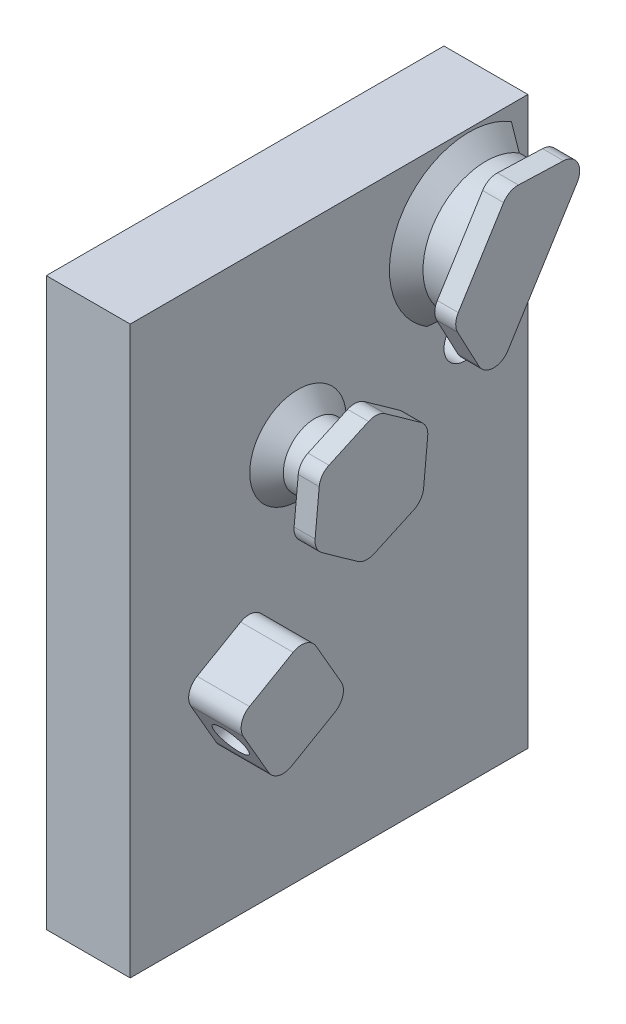
from build123d import *

# Parameters (mm, degrees)
SKETCH1_W           = 60.198
SKETCH1_H           = 85.725
SKETCH1_R           = 3.175
BOSS_EXTRUDE1_DEPTH = 12.7
SKETCH3_R           = 4.7625
BOSS_EXTRUDE2_DEPTH = 7.9375
BOSS_EXTRUDE3_DEPTH = 3.175
BOSS_EXTRUDE4_DEPTH = 3.175
FILLET1_R           = 2.54
CHAMFER1_SIZE       = 2.54
SKETCH15_R          = 2.54
CUT_EXTRUDE1_DEPTH  = 12.7


with BuildPart() as part:
    # Sketch1 → Boss-Extrude1 (new body)
    with BuildSketch(Plane(origin=(0, 0, 0), x_dir=(0, 0, -1), z_dir=(1, 0, 0))):
        with Locations((30.099, 42.8625)):
            Rectangle(SKETCH1_W, SKETCH1_H)
        with Locations((50.673, 58.7375)):
            Circle(SKETCH1_R, mode=Mode.SUBTRACT)
    extrude(amount=-BOSS_EXTRUDE1_DEPTH)

    # Sketch3 → Boss-Extrude2 (add)
    with BuildSketch(Plane(origin=(0, 0, 0), x_dir=(0, 0, -1), z_dir=(1, 0, 0))):
        with Locations((25.4, 57.15)):
            Circle(SKETCH3_R)
        Polygon((18.923, 39.573522628), (25.273, 28.575), (14.274477372, 22.225), (7.924477372, 33.223522628), align=None)
        with BuildLine():
            Line((56.355023328, 81.24857189), (46.259909872, 65.09335031))
            ThreePointArc((46.259909872, 65.09335031), (43.22985581, 78.218517828), (56.355023328, 81.24857189))
        make_face()
    extrude(amount=BOSS_EXTRUDE2_DEPTH)

    # Sketch10 → Boss-Extrude3 (add)
    with BuildSketch(Plane(origin=(7.9375, 0, 0), x_dir=(0, 0, -1), z_dir=(1, 0, 0))):
        Polygon((26.305931595, 66.631820128), (17.641468693, 62.67546984), (16.735537097, 53.193649712), (24.494068405, 47.668179872), (33.158531307, 51.62453016), (34.064462903, 61.106350288), align=None)
    extrude(amount=BOSS_EXTRUDE3_DEPTH)

    # Sketch14 → Boss-Extrude4 (add)
    with BuildSketch(Plane(origin=(7.9375, 0, 0), x_dir=(0, 0, -1), z_dir=(1, 0, 0))):
        Polygon((51.3074666, 73.1709611), (58.881956407, 85.29242578), (46.18969706, 85.735768391), (37.770793083, 72.262986752), (43.732976793, 61.04949642), align=None)
    extrude(amount=BOSS_EXTRUDE4_DEPTH)

    # Fillet1
    fillet1_edges = [part.edges().sort_by_distance(p)[0] for p in [
        (3.96875, 39.573522628, -18.923),
        (3.96875, 33.223522628, -7.924477372),
        (3.96875, 22.225, -14.274477372),
        (3.96875, 28.575, -25.273),
        (9.525, 61.106350288, -34.064462903),
        (9.525, 66.631820128, -26.305931595),
        (9.525, 62.67546984, -17.641468693),
        (9.525, 53.193649712, -16.735537097),
        (9.525, 47.668179872, -24.494068405),
        (9.525, 51.62453016, -33.158531307),
        (9.525, 61.04949642, -43.732976793),
        (9.525, 85.29242578, -58.881956407),
        (9.525, 85.735768391, -46.18969706),
        (9.525, 72.262986752, -37.770793083),
    ]]
    fillet(fillet1_edges, radius=FILLET1_R)

    # Chamfer1
    chamfer1_edges = [part.edges().sort_by_distance(p)[0] for p in [
        (0, 57.15, -20.6375),
        (0, 78.218517828, -43.22985581),
    ]]
    chamfer(chamfer1_edges, length=CHAMFER1_SIZE)

    # Sketch15 → Cut-Extrude1 (cut)
    with BuildSketch(Plane(origin=(0, 18.087280015, -31.328087957), x_dir=(-1, 0, 0), z_dir=(0, 0.5, -0.866025404))):
        with Locations((-4.114917268, 18.460175913)):
            Circle(SKETCH15_R)
    extrude(amount=-CUT_EXTRUDE1_DEPTH, mode=Mode.SUBTRACT)


solid = part.part
